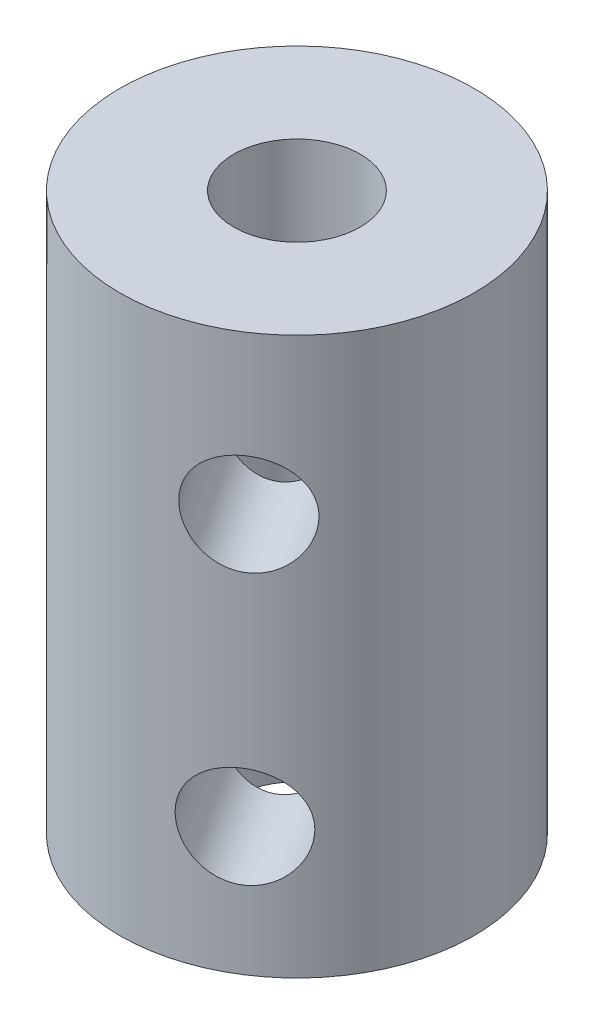
from build123d import *

# Parameters (mm, degrees)
SKETCH_1_R           = 7
SKETCH_1_R_2         = 2.5
EXTRUDE_1_DEPTH      = 22
MM_1_REACH           = 25.055
MM_1_BORE_R          = 2
MM_1_ON_FACE_2_REACH = 25.854
MM_1_BORE_2_R        = 2


with BuildPart() as part:
    # 草图1 → 凸台-拉伸1 (new body)
    with BuildSketch(Plane(origin=(0, 0, 0), x_dir=(1, 0, 0), z_dir=(0, 1, 0))):
        with Locations(Location((0, 0, 0), (0, 0, 270))):
            Circle(SKETCH_1_R)
        with Locations(Location((0, 0, 0), (0, 0, 270))):
            Circle(SKETCH_1_R_2, mode=Mode.SUBTRACT)
    extrude(amount=EXTRUDE_1_DEPTH)

    # 大小mm 暗销孔1 bore (on position points) → 大小mm 暗销孔1 (cut, up to next)
    with BuildSketch(Plane(origin=(3.857759844, 15.771125488, 5.841034924), x_dir=(0.834433560595, 0, -0.551108549156), z_dir=(0.551108549156, 0, 0.834433560595)), mode=Mode.PRIVATE) as mm_1_sk1:
        Circle(MM_1_BORE_R)
    mm_1_tool1 = extrude(mm_1_sk1.sketch, amount=-MM_1_REACH, mode=Mode.PRIVATE) & part.part
    add(mm_1_tool1.solids().sort_by_distance((3.85776, 15.771125, 5.841035))[0], mode=Mode.SUBTRACT)

    # 大小mm 暗销孔1 bore 2 (on position points) → 大小mm 暗销孔1 on face 2 (cut, up to next)
    with BuildSketch(Plane(origin=(3.760299327, 5.067053502, 5.904248383), x_dir=(0.843463865935, 0, -0.537185914616), z_dir=(0.537185914616, 0, 0.843463865935)), mode=Mode.PRIVATE) as mm_1_on_face_2_sk1:
        Circle(MM_1_BORE_2_R)
    mm_1_on_face_2_tool1 = extrude(mm_1_on_face_2_sk1.sketch, amount=-MM_1_ON_FACE_2_REACH, mode=Mode.PRIVATE) & part.part
    add(mm_1_on_face_2_tool1.solids().sort_by_distance((3.760299, 5.067054, 5.904248))[0], mode=Mode.SUBTRACT)


solid = part.part
